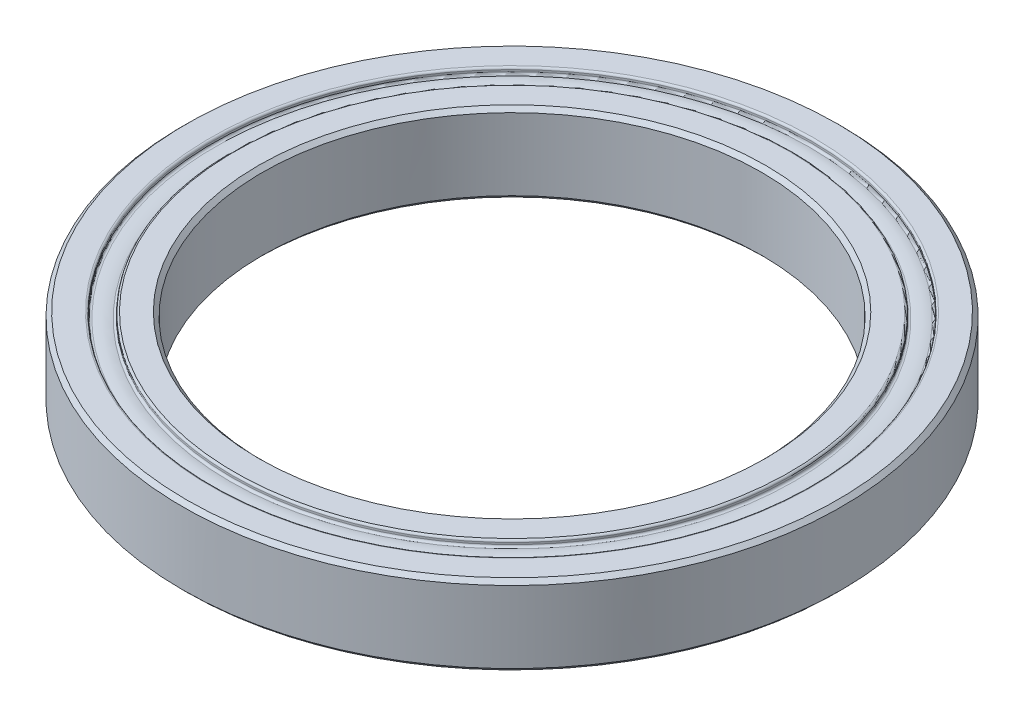
from build123d import *

# Parameters (mm, degrees)
CHAMFER_1_SIZE = 0.4


with BuildPart() as part:
    # 草图1 → 旋转1 (revolve)
    with BuildSketch(Plane.XY):
        with BuildLine():
            Line((-25, 8), (-25, 0))
            Line((-25, 0), (-27.8, 0))
            ThreePointArc((-27.8, 0), (-27.941421356, 0.058578644), (-28, 0.2))
            Line((-28, 0.2), (-28, 0.387521626))
            ThreePointArc((-28, 0.387521626), (-28.074797461, 0.5434842), (-28.243243243, 0.582790728))
            ThreePointArc((-28.243243243, 0.582790728), (-29, 0.5), (-29.756756757, 0.582790728))
            ThreePointArc((-29.756756757, 0.582790728), (-29.925202539, 0.5434842), (-30, 0.387521626))
            Line((-30, 0.387521626), (-30, 0.2))
            ThreePointArc((-30, 0.2), (-30.058578644, 0.058578644), (-30.2, 0))
            Line((-30.2, 0), (-33, 0))
            Line((-33, 0), (-33, 8))
            Line((-33, 8), (-30.2, 8))
            ThreePointArc((-30.2, 8), (-30.058578644, 7.941421356), (-30, 7.8))
            Line((-30, 7.8), (-30, 7.612478374))
            ThreePointArc((-30, 7.612478374), (-29.925202539, 7.4565158), (-29.756756757, 7.417209272))
            ThreePointArc((-29.756756757, 7.417209272), (-29, 7.5), (-28.243243243, 7.417209272))
            ThreePointArc((-28.243243243, 7.417209272), (-28.074797461, 7.4565158), (-28, 7.612478374))
            Line((-28, 7.612478374), (-28, 7.8))
            ThreePointArc((-28, 7.8), (-27.941421356, 7.941421356), (-27.8, 8))
            Line((-27.8, 8), (-25, 8))
        make_face()
    revolve(axis=Axis((0, 0, 0), (0, 1, 0)))

    # 倒角1
    chamfer_1_edges = [part.edges().sort_by_distance(p)[0] for p in [
        (33, 8, 0),
        (33, 0, 0),
        (25, 0, 0),
        (25, 8, 0),
    ]]
    chamfer(chamfer_1_edges, length=CHAMFER_1_SIZE)


solid = part.part
